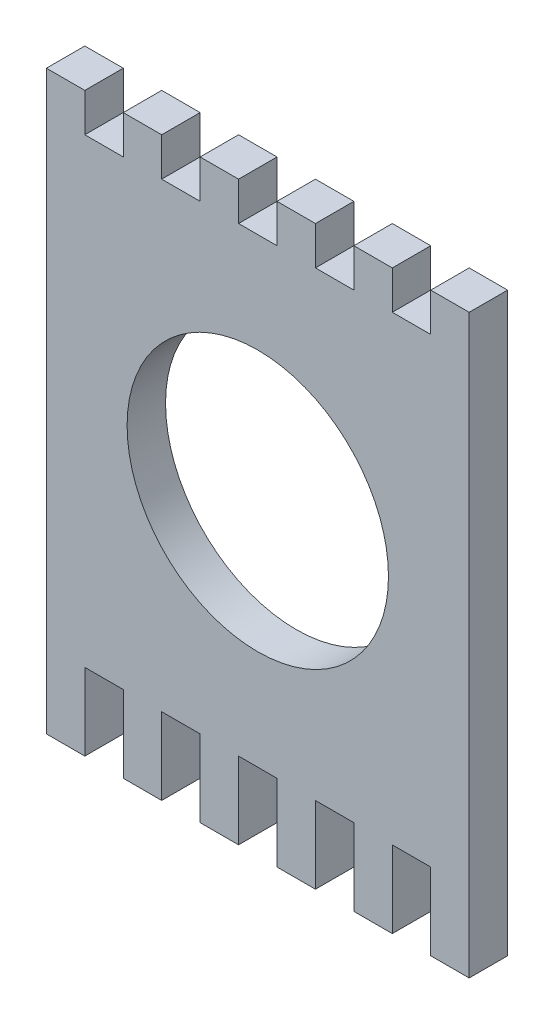
from build123d import *

# Parameters (mm, degrees)
ESQUISSE1_W        = 55
ESQUISSE1_H        = 60
ESQUISSE1_R        = 17
ESQUISSE1_W_2      = 5
ESQUISSE1_H_2      = 5
ESQUISSE1_H_3      = 10
BOSS_EXTRU_1_DEPTH = 5


with BuildPart() as part:
    # Esquisse1 → Boss.-Extru.1 (new body)
    with BuildSketch(Plane.XY):
        with Locations((27.5, 30)):
            Rectangle(ESQUISSE1_W, ESQUISSE1_H)
        with Locations((27.5, 30)):
            Circle(ESQUISSE1_R, mode=Mode.SUBTRACT)
        with Locations((12.5, 62.5)):
            Rectangle(ESQUISSE1_W_2, ESQUISSE1_H_2)
        with Locations((2.5, 62.5)):
            Rectangle(ESQUISSE1_W_2, ESQUISSE1_H_2)
        with Locations((22.5, 62.5)):
            Rectangle(ESQUISSE1_W_2, ESQUISSE1_H_2)
        with Locations((32.5, 62.5)):
            Rectangle(ESQUISSE1_W_2, ESQUISSE1_H_2)
        with Locations((52.5, 62.5)):
            Rectangle(ESQUISSE1_W_2, ESQUISSE1_H_2)
        with Locations((42.5, 62.5)):
            Rectangle(ESQUISSE1_W_2, ESQUISSE1_H_2)
        with Locations((2.5, -5)):
            Rectangle(ESQUISSE1_W_2, ESQUISSE1_H_3)
        with Locations((12.5, -5)):
            Rectangle(ESQUISSE1_W_2, ESQUISSE1_H_3)
        with Locations((22.5, -5)):
            Rectangle(ESQUISSE1_W_2, ESQUISSE1_H_3)
        with Locations((32.5, -5)):
            Rectangle(ESQUISSE1_W_2, ESQUISSE1_H_3)
        with Locations((42.5, -5)):
            Rectangle(ESQUISSE1_W_2, ESQUISSE1_H_3)
        with Locations((52.5, -5)):
            Rectangle(ESQUISSE1_W_2, ESQUISSE1_H_3)
    extrude(amount=BOSS_EXTRU_1_DEPTH)


solid = part.part
